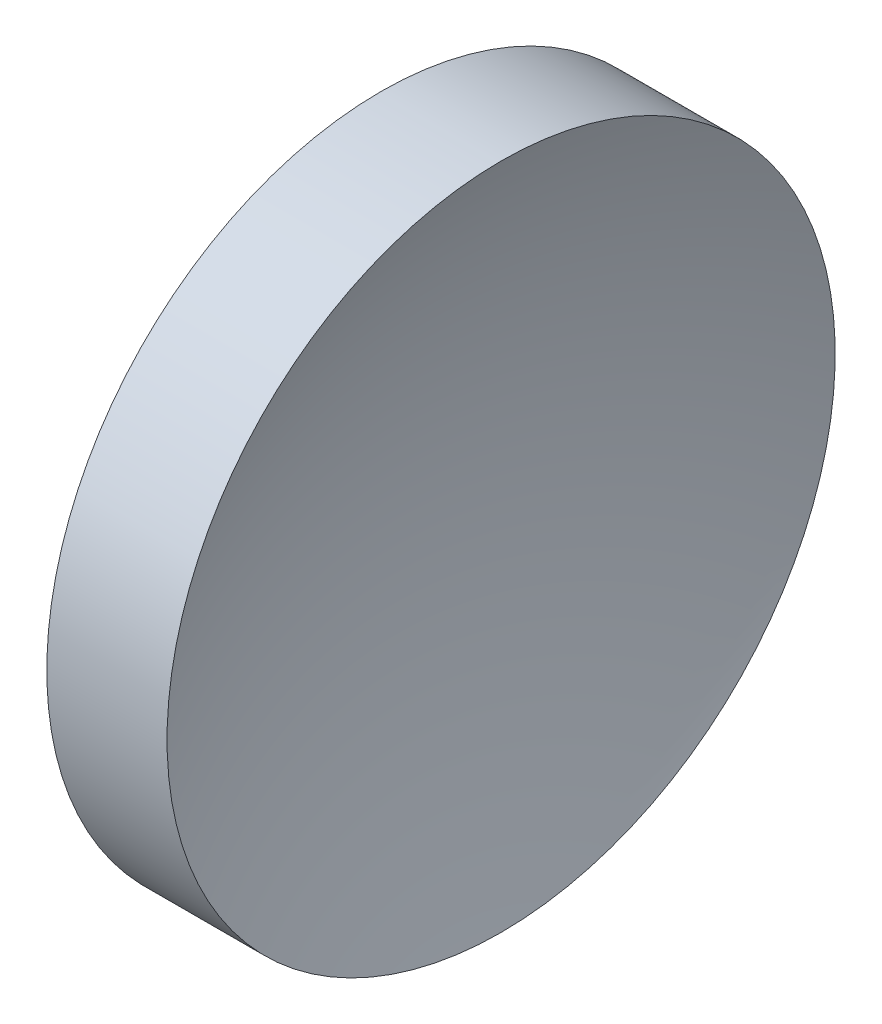
from build123d import *


with BuildPart() as part:
    # 草图1 → 旋转1 (revolve)
    with BuildSketch(Plane.XY, mode=Mode.PRIVATE) as revolve_1_sk:
        with BuildLine():
            Line((57.358190158, 32.578725913), (57.358190158, 45.078725913))
            Line((57.358190158, 45.078725913), (61.858210494, 45.078725913))
            ThreePointArc((61.858210494, 45.078725913), (59.989328168, 38.952501352), (59.358190158, 32.578725913))
            Line((59.358190158, 32.578725913), (57.358190158, 32.578725913))
        make_face()
    revolve(revolve_1_sk.sketch.rotate(Axis((55.007394624, 32.578725913, 0), (1, 0, 0)), 180), axis=Axis((55.007394624, 32.578725913, 0), (1, 0, 0)))  # turned: the seam where the file's is


solid = part.part
